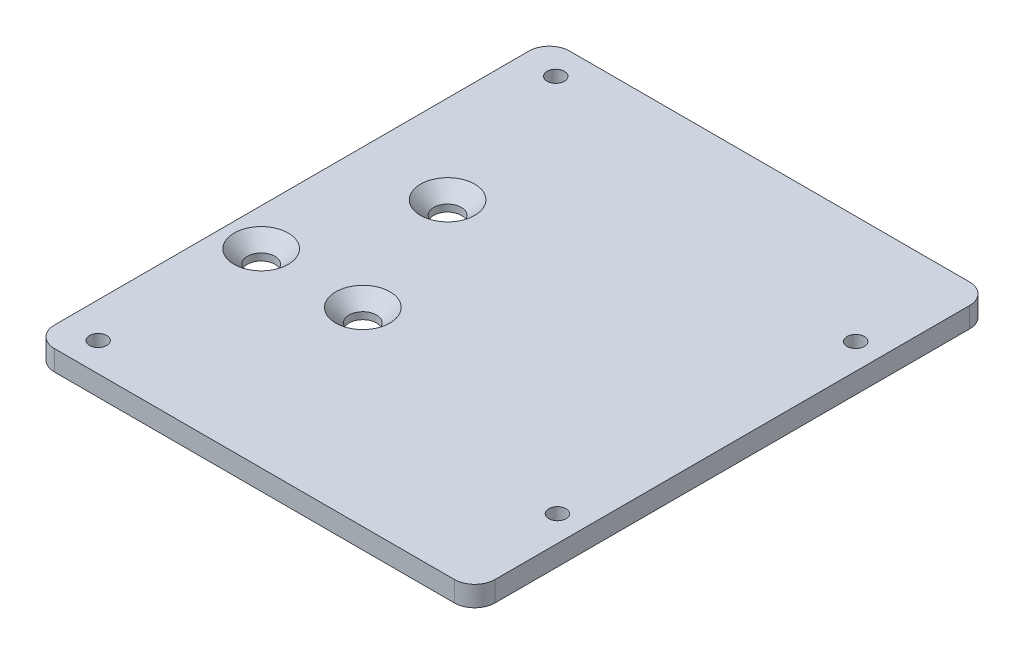
from build123d import *

# Parameters (mm, degrees)
SKETCH_1_W               = 65
SKETCH_1_H               = 76
EXTRUDE_1_DEPTH          = 3
FILLET_1_R               = 3
SKETCH_3_R               = 1.275
CUT_EXTRUDE_1_DEPTH      = 1
CUT_EXTRUDE_1_DEPTH_BACK = 4
SKETCH_6_R               = 2.025
CUT_EXTRUDE_3_DEPTH      = 10
HOLE_WIZARD_1_AT_2_COUNT = 2
HOLE_WIZARD_1_AT_2_PITCH = 15
HOLE_WIZARD_1_AT_3_COUNT = 2
HOLE_WIZARD_1_AT_3_PITCH = 21.360009363


with BuildPart() as part:
    # 草图1 → 凸台-拉伸1 (new body)
    with BuildSketch(Plane(origin=(0, 0, 0), x_dir=(1, 0, 0), z_dir=(0, 1, 0))):
        Rectangle(SKETCH_1_W, SKETCH_1_H)
    extrude(amount=EXTRUDE_1_DEPTH)

    # 圆角1
    fillet_1_edges = [part.edges().sort_by_distance(p)[0] for p in [
        (32.5, 1.5, 38),
        (-32.5, 1.5, 38),
        (-32.5, 1.5, -38),
        (32.5, 1.5, -38),
    ]]
    fillet(fillet_1_edges, radius=FILLET_1_R)

    # 草图3 → 切除-拉伸1 (cut, two sides)
    with BuildSketch(Plane(origin=(0, 3, 0), x_dir=(1, 0, 0), z_dir=(0, 1, 0))) as cut_extrude_1_sk:
        with Locations((28.7, -22)):
            Circle(SKETCH_3_R)
        with Locations((28.7, 22)):
            Circle(SKETCH_3_R)
        with Locations((-27.3, 33.75)):
            Circle(SKETCH_3_R)
        with Locations((-27.3, -33.75)):
            Circle(SKETCH_3_R)
    extrude(amount=CUT_EXTRUDE_1_DEPTH, mode=Mode.SUBTRACT)
    extrude(cut_extrude_1_sk.sketch, amount=-CUT_EXTRUDE_1_DEPTH_BACK, mode=Mode.SUBTRACT)

    # 草图6 → 切除-拉伸3 (cut)
    with BuildSketch(Plane(origin=(0, 3, 0), x_dir=(1, 0, 0), z_dir=(0, 1, 0))):
        with Locations((-27, -10)):
            Circle(SKETCH_6_R)
        with Locations((-12, -10)):
            Circle(SKETCH_6_R)
        with Locations((-19.5, 10)):
            Circle(SKETCH_6_R)
    extrude(amount=-CUT_EXTRUDE_3_DEPTH, mode=Mode.SUBTRACT)

    # 草图7 → 孔1 (revolve, cut)
    with BuildSketch(Plane(origin=(-12, 3, 10), x_dir=(0, 0, 1), z_dir=(1, 0, 0))):
        Polygon((0, 0), (0, 3), (2, 3), (2, 2), (4, 0), align=None)
    hole_wizard_1 = revolve(axis=Axis((-12, 9.445314094, 10), (0, -1, 0)), mode=Mode.SUBTRACT)

    # 孔1 at 2: 孔1 ×2
    with Locations(*[(-i * HOLE_WIZARD_1_AT_2_PITCH, 0, 0) for i in range(1, HOLE_WIZARD_1_AT_2_COUNT)]):
        add(hole_wizard_1, mode=Mode.SUBTRACT)

    # 孔1 at 3: 孔1 ×2
    with Locations(*[Vector(-0.351123442, 0, -0.936329178) * (i * HOLE_WIZARD_1_AT_3_PITCH) for i in range(1, HOLE_WIZARD_1_AT_3_COUNT)]):
        add(hole_wizard_1, mode=Mode.SUBTRACT)


solid = part.part
